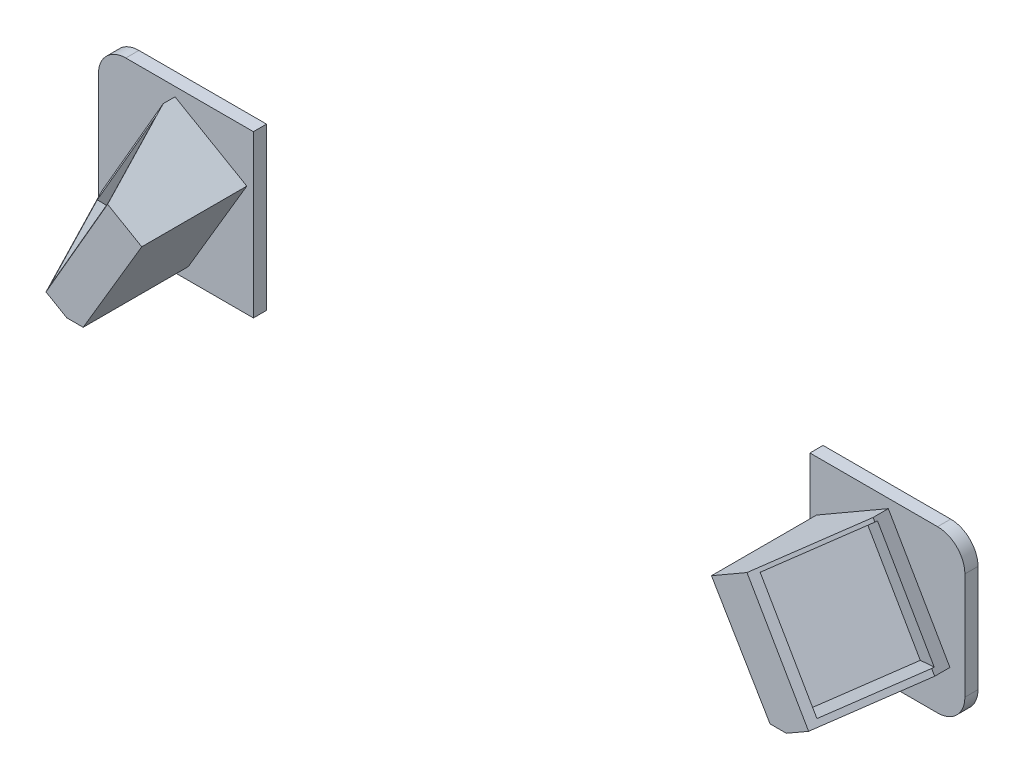
from build123d import *

# Parameters (mm, degrees)
AUFSATZ_LINEAR_AUSTRAGEN1_DEPTH   = 3
AUFSATZ_LINEAR_AUSTRAGEN1_2_DEPTH = 3
AUFSATZ_LINEAR_AUSTRAGEN2_DEPTH   = 24
SCHNITT_LINEAR_AUSTRAGEN2_DEPTH   = 121.161965349
SCHNITT_LINEAR_AUSTRAGEN3_DEPTH   = 54
SKIZZE7_W                         = 20.151946154
SKIZZE7_H                         = 26.896200326
SCHNITT_LINEAR_AUSTRAGEN4_DEPTH   = 9
SKIZZE8_W                         = 21.124076697
SKIZZE8_H                         = 25.941583557
SCHNITT_LINEAR_AUSTRAGEN5_DEPTH   = 9


with BuildPart() as part:
    # Skizze1 → Aufsatz-Linear austragen1 (new body)
    with BuildSketch(Plane.XY.offset(200.684819625)):
        with BuildLine():
            Line((42.046255802, 20.93937831), (71.202450647, 20.93937831))
            ThreePointArc((71.202450647, 20.93937831), (75.616222333, 22.767622404), (77.444466427, 27.181394091))
            Line((77.444466427, 27.181394091), (77.444466427, 51.562209578))
            ThreePointArc((77.444466427, 51.562209578), (75.616222333, 55.975981265), (71.202450647, 57.804225359))
            Line((71.202450647, 57.804225359), (42.046255802, 57.804225359))
            Line((42.046255802, 57.804225359), (42.046255802, 20.93937831))
        make_face()
    extrude(amount=AUFSATZ_LINEAR_AUSTRAGEN1_DEPTH)

    # Skizze3 → Aufsatz-Linear austragen2 (add)
    with BuildSketch(Plane.XY.offset(203.684819625)):
        Polygon((59.953619506, 55.745700513), (74.030511905, 31.363807665), (60.666568647, 23.648131427), (56.936007357, 23.648131427), (43.55153333, 46.275951643), align=None)
        Polygon((-103.006425052, 55.745700513), (-117.083317451, 31.363807665), (-103.719374193, 23.648131427), (-99.988812903, 23.648131427), (-86.604338875, 46.275951643), align=None)
    extrude(amount=AUFSATZ_LINEAR_AUSTRAGEN2_DEPTH)

    # Skizze4 → Schnitt-Linear austragen2 (cut, through all)
    with BuildSketch(Plane(origin=(4.926700878, -8.533296234, 0), x_dir=(-0.866025404, -0.5, 0), z_dir=(0.5, -0.866025404, 0))):
        Polygon((-80.497261448, -205.66236291), (-69.016877495, -230.282125747), (-80.497261448, -230.282125747), align=None)
    extrude(amount=-SCHNITT_LINEAR_AUSTRAGEN2_DEPTH, mode=Mode.SUBTRACT)

    # Skizze6 → Schnitt-Linear austragen3 (cut)
    with BuildSketch(Plane(origin=(-15.689902264, -27.175707887, 0), x_dir=(0.866025404, -0.5, 0), z_dir=(-0.5, -0.866025404, 0))):
        Polygon((-117.901019581, 204.624426213), (-104.683579141, 232.969318707), (-117.901019581, 232.969318707), align=None)
    extrude(amount=-SCHNITT_LINEAR_AUSTRAGEN3_DEPTH, mode=Mode.SUBTRACT)

    # Skizze7 → Schnitt-Linear austragen4 (cut)
    with BuildSketch(Plane(origin=(-151.743992107, 87.609434691, 81.705900646), x_dir=(0.365998151, -0.211309131, 0.906307787), z_dir=(-0.784885567, 0.453153894, 0.422618262))):
        with Locations((150.282281882, -17.043094839)):
            Rectangle(SKIZZE7_W, SKIZZE7_H)
    extrude(amount=-SCHNITT_LINEAR_AUSTRAGEN4_DEPTH, mode=Mode.SUBTRACT)

    # Skizze8 → Schnitt-Linear austragen5 (cut)
    with BuildSketch(Plane(origin=(125.481198092, 72.446603496, 67.564812035), x_dir=(0.365998151, 0.211309131, -0.906307787), z_dir=(0.784885567, 0.453153894, 0.422618262))):
        with Locations((-164.074275128, 4.496338843)):
            Rectangle(SKIZZE8_W, SKIZZE8_H)
    extrude(amount=-SCHNITT_LINEAR_AUSTRAGEN5_DEPTH, mode=Mode.SUBTRACT)


with BuildPart() as body_2:
    # Skizze1 → Aufsatz-Linear austragen1 2 (new body)
    with BuildSketch(Plane.XY.offset(200.684819625)):
        with BuildLine():
            Line((-85.099061347, 57.804225359), (-85.099061347, 20.93937831))
            Line((-85.099061347, 20.93937831), (-114.255256192, 20.93937831))
            ThreePointArc((-114.255256192, 20.93937831), (-118.669027879, 22.767622404), (-120.497271973, 27.181394091))
            Line((-120.497271973, 27.181394091), (-120.497271973, 51.562209578))
            ThreePointArc((-120.497271973, 51.562209578), (-118.669027879, 55.975981265), (-114.255256192, 57.804225359))
            Line((-114.255256192, 57.804225359), (-85.099061347, 57.804225359))
        make_face()
    extrude(amount=AUFSATZ_LINEAR_AUSTRAGEN1_2_DEPTH)


solid = Compound([part.part, body_2.part])
